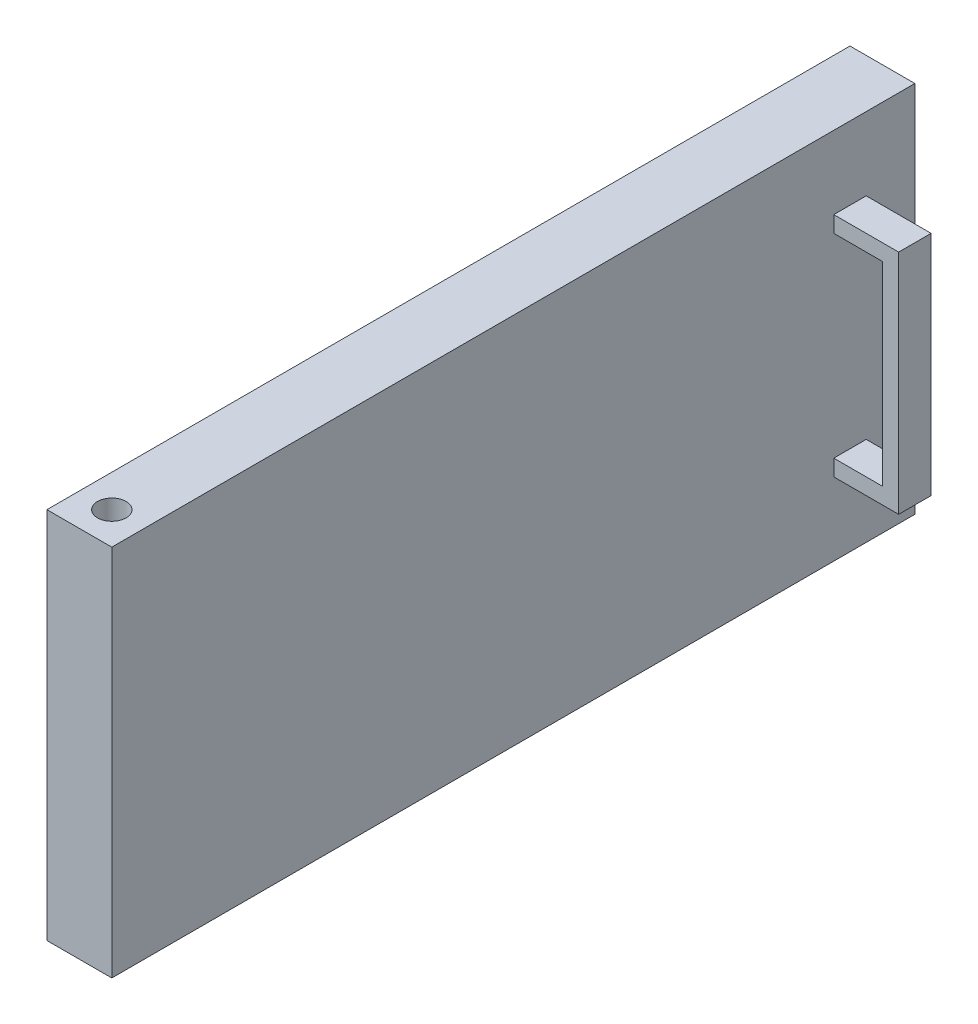
from build123d import *

# Parameters (mm, degrees)
SKETCH1_W           = 247.5
SKETCH1_H           = 115
BOSS_EXTRUDE1_DEPTH = 20
SKETCH2_R           = 4.4
CUT_EXTRUDE1_DEPTH  = 17.5
SKETCH3_R           = 4.4
CUT_EXTRUDE2_DEPTH  = 17.5
SKETCH6_W           = 10
SKETCH6_H           = 70
BOSS_EXTRUDE3_DEPTH = 20
SKETCH7_W           = 15
SKETCH7_H           = 60
CUT_EXTRUDE4_DEPTH  = 20


with BuildPart() as part:
    # Sketch1 → Boss-Extrude1 (new body)
    with BuildSketch(Plane(origin=(0, 0, 0), x_dir=(0, 0, -1), z_dir=(1, 0, 0))):
        Rectangle(SKETCH1_W, SKETCH1_H)
    extrude(amount=BOSS_EXTRUDE1_DEPTH)

    # Sketch2 → Cut-Extrude1 (cut)
    with BuildSketch(Plane(origin=(0, 57.5, 0), x_dir=(1, 0, 0), z_dir=(0, 1, 0))):
        with Locations((10, -113.75)):
            Circle(SKETCH2_R)
    extrude(amount=-CUT_EXTRUDE1_DEPTH, mode=Mode.SUBTRACT)

    # Sketch3 → Cut-Extrude2 (cut)
    with BuildSketch(Plane.XZ.offset(57.5)):
        with Locations((10, 113.75)):
            Circle(SKETCH3_R)
    extrude(amount=-CUT_EXTRUDE2_DEPTH, mode=Mode.SUBTRACT)

    # Sketch6 → Boss-Extrude3 (add)
    with BuildSketch(Plane(origin=(20, 0, 0), x_dir=(0, 0, -1), z_dir=(1, 0, 0))):
        with Locations((103.75, 0)):
            Rectangle(SKETCH6_W, SKETCH6_H)
    extrude(amount=BOSS_EXTRUDE3_DEPTH)

    # Sketch7 → Cut-Extrude4 (cut)
    with BuildSketch(Plane(origin=(0, 0, -108.75), x_dir=(-1, 0, 0), z_dir=(0, 0, -1))):
        with Locations((-27.5, 0)):
            Rectangle(SKETCH7_W, SKETCH7_H)
    extrude(amount=-CUT_EXTRUDE4_DEPTH, mode=Mode.SUBTRACT)


solid = part.part
